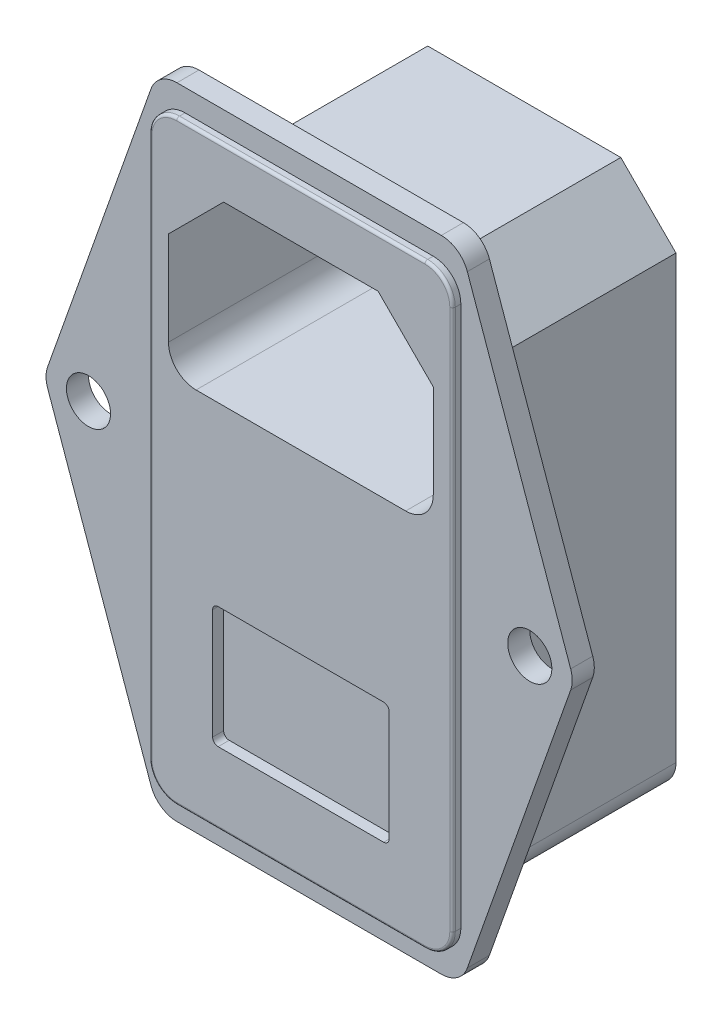
from build123d import *

# Parameters (mm, degrees)
SKETCH1_R           = 2
BOSS_EXTRUDE1_DEPTH = 2
BOSS_EXTRUDE2_DEPTH = 0.75
FILLET1_R           = 0.25
BOSS_EXTRUDE3_DEPTH = 17.5
CUT_EXTRUDE1_DEPTH  = 17.5
CUT_EXTRUDE2_DEPTH  = 1


with BuildPart() as part:
    # Sketch1 → Boss-Extrude1 (new body)
    with BuildSketch(Plane.XY):
        with BuildLine():
            Line((28.089158303, 56.333113093), (37.455537614, 29.833113093))
            ThreePointArc((37.455537614, 29.833113093), (37.598437155, 29), (37.455537614, 28.166886907))
            Line((37.455537614, 28.166886907), (28.089158303, 1.666886907))
            ThreePointArc((28.089158303, 1.666886907), (27.175528881, 0.458825983), (25.732057844, 0))
            Line((25.732057844, 0), (1.767942156, 0))
            ThreePointArc((1.767942156, 0), (0.324471119, 0.458825983), (-0.589158303, 1.666886907))
            Line((-0.589158303, 1.666886907), (-9.955537614, 28.166886907))
            ThreePointArc((-9.955537614, 28.166886907), (-10.098437155, 29), (-9.955537614, 29.833113093))
            Line((-9.955537614, 29.833113093), (-0.589158303, 56.333113093))
            ThreePointArc((-0.589158303, 56.333113093), (0.324471119, 57.541174017), (1.767942156, 58))
            Line((1.767942156, 58), (25.732057844, 58))
            ThreePointArc((25.732057844, 58), (27.175528881, 57.541174017), (28.089158303, 56.333113093))
        make_face()
        with Locations((-6.25, 29)):
            Circle(SKETCH1_R, mode=Mode.SUBTRACT)
        with Locations((33.75, 29)):
            Circle(SKETCH1_R, mode=Mode.SUBTRACT)
    extrude(amount=BOSS_EXTRUDE1_DEPTH)

    # Sketch2 → Boss-Extrude2 (add)
    with BuildSketch(Plane.XY.offset(2)):
        with BuildLine():
            Line((2.5, 2), (25, 2))
            ThreePointArc((25, 2), (26.767766953, 2.732233047), (27.5, 4.5))
            Line((27.5, 4.5), (27.5, 53.5))
            ThreePointArc((27.5, 53.5), (26.767766953, 55.267766953), (25, 56))
            Line((25, 56), (2.5, 56))
            ThreePointArc((2.5, 56), (0.732233047, 55.267766953), (0, 53.5))
            Line((0, 53.5), (0, 4.5))
            ThreePointArc((0, 4.5), (0.732233047, 2.732233047), (2.5, 2))
        make_face()
    extrude(amount=BOSS_EXTRUDE2_DEPTH)

    # Fillet1
    fillet1_edges = [part.edges().sort_by_distance(p)[0] for p in [
        (0.732233047, 2.732233047, 2.75),
        (13.75, 2, 2.75),
        (26.767766953, 2.732233047, 2.75),
        (27.5, 29, 2.75),
        (26.767766953, 55.267766953, 2.75),
        (13.75, 56, 2.75),
        (0.732233047, 55.267766953, 2.75),
        (0, 29, 2.75),
    ]]
    fillet(fillet1_edges, radius=FILLET1_R)

    # Sketch3 → Boss-Extrude3 (add)
    with BuildSketch(Plane(origin=(0, 0, 0), x_dir=(-1, 0, 0), z_dir=(0, 0, -1))):
        with BuildLine():
            Line((-27.5, 47.75), (-22.5, 52.75))
            Line((-22.5, 52.75), (-5, 52.75))
            Line((-5, 52.75), (0, 47.75))
            Line((0, 47.75), (0, 7.75))
            ThreePointArc((0, 7.75), (-0.732233047, 5.982233047), (-2.5, 5.25))
            Line((-2.5, 5.25), (-25, 5.25))
            ThreePointArc((-25, 5.25), (-26.767766953, 5.982233047), (-27.5, 7.75))
            Line((-27.5, 7.75), (-27.5, 47.75))
        make_face()
    extrude(amount=BOSS_EXTRUDE3_DEPTH)

    # Sketch4 → Cut-Extrude1 (cut)
    with BuildSketch(Plane.XY.offset(2.75)):
        with BuildLine():
            Line((1.75, 46.5), (6.75, 51.5))
            Line((6.75, 51.5), (20.75, 51.5))
            Line((20.75, 51.5), (25.75, 46.5))
            Line((25.75, 46.5), (25.75, 38))
            ThreePointArc((25.75, 38), (25.017766953, 36.232233047), (23.25, 35.5))
            Line((23.25, 35.5), (4.25, 35.5))
            ThreePointArc((4.25, 35.5), (2.482233047, 36.232233047), (1.75, 38))
            Line((1.75, 38), (1.75, 46.5))
        make_face()
    extrude(amount=-CUT_EXTRUDE1_DEPTH, mode=Mode.SUBTRACT)

    # Sketch5 → Cut-Extrude2 (cut)
    with BuildSketch(Plane.XY.offset(2.75)):
        with BuildLine():
            Line((6.25, 19.5), (21.25, 19.5))
            ThreePointArc((21.25, 19.5), (21.603553391, 19.353553391), (21.75, 19))
            Line((21.75, 19), (21.75, 9))
            ThreePointArc((21.75, 9), (21.603553391, 8.646446609), (21.25, 8.5))
            Line((21.25, 8.5), (6.25, 8.5))
            ThreePointArc((6.25, 8.5), (5.896446609, 8.646446609), (5.75, 9))
            Line((5.75, 9), (5.75, 19))
            ThreePointArc((5.75, 19), (5.896446609, 19.353553391), (6.25, 19.5))
        make_face()
    extrude(amount=-CUT_EXTRUDE2_DEPTH, mode=Mode.SUBTRACT)


solid = part.part
